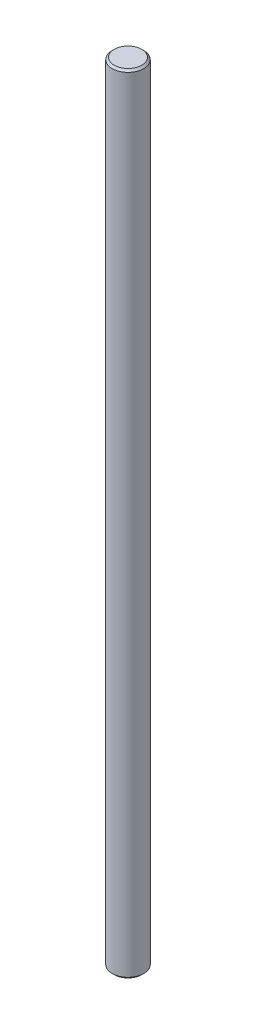
from build123d import *

# Parameters (mm, degrees)
SKETCH1_R           = 2
BOSS_EXTRUDE1_DEPTH = 50
CHAMFER1_SIZE       = 0.25


with BuildPart() as part:
    # Sketch1 → Boss-Extrude1 (new body, symmetric)
    with BuildSketch(Plane(origin=(0, 0, 0), x_dir=(1, 0, 0), z_dir=(0, 1, 0))):
        Circle(SKETCH1_R)
    extrude(amount=BOSS_EXTRUDE1_DEPTH, both=True)

    # Chamfer1
    chamfer1_edges = [part.edges().sort_by_distance(p)[0] for p in [
        (-2, -50, 0),
        (-2, 50, 0),
    ]]
    chamfer(chamfer1_edges, length=CHAMFER1_SIZE)


solid = part.part
